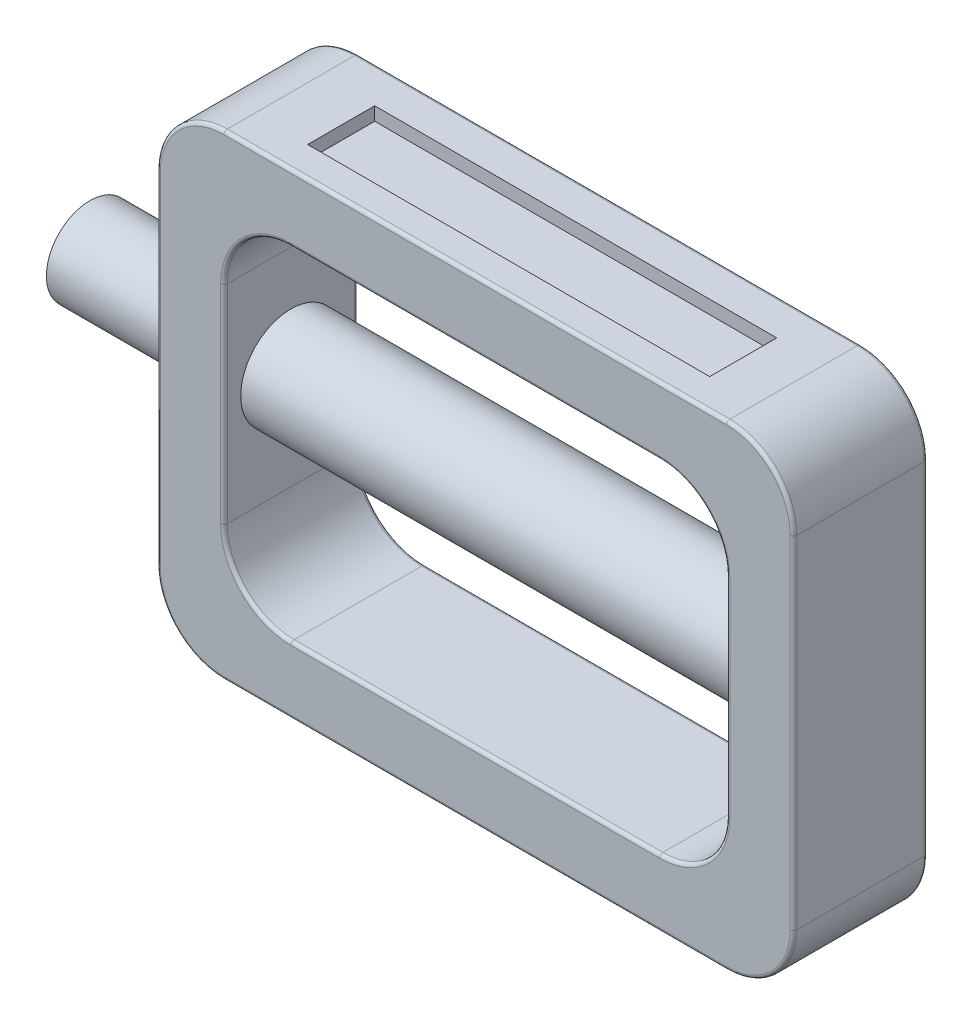
from build123d import *

# Parameters (mm, degrees)
BOSS_EXTRUDE1_DEPTH = 20
SKETCH2_R           = 7.5
BOSS_EXTRUDE2_DEPTH = 85
SKETCH4_R           = 6.5
BOSS_EXTRUDE3_DEPTH = 20
SKETCH5_W           = 60
SKETCH5_H           = 10
CUT_EXTRUDE1_DEPTH  = 2
FILLET1_R           = 0.5
FILLET2_R           = 0.5


with BuildPart() as part:
    # Sketch1 → Boss-Extrude1 (new body)
    with BuildSketch(Plane.XY):
        with BuildLine():
            Line((0, 0), (0, 25.5))
            ThreePointArc((0, 25.5), (2.928932188, 32.571067812), (10, 35.5))
            Line((10, 35.5), (85, 35.5))
            ThreePointArc((85, 35.5), (92.071067812, 32.571067812), (95, 25.5))
            Line((95, 25.5), (95, -25.5))
            ThreePointArc((95, -25.5), (92.071067812, -32.571067812), (85, -35.5))
            Line((85, -35.5), (10, -35.5))
            ThreePointArc((10, -35.5), (2.928932188, -32.571067812), (0, -25.5))
            Line((0, -25.5), (0, 0))
        make_face()
        with BuildLine():
            Line((10, 0), (10, 15.5))
            ThreePointArc((10, 15.5), (12.928932188, 22.571067812), (20, 25.5))
            Line((20, 25.5), (75, 25.5))
            ThreePointArc((75, 25.5), (82.071067812, 22.571067812), (85, 15.5))
            Line((85, 15.5), (85, 0))
            Line((85, 0), (85, -15.5))
            ThreePointArc((85, -15.5), (82.071067812, -22.571067812), (75, -25.5))
            Line((75, -25.5), (20, -25.5))
            ThreePointArc((20, -25.5), (12.928932188, -22.571067812), (10, -15.5))
            Line((10, -15.5), (10, 0))
        make_face(mode=Mode.SUBTRACT)
    extrude(amount=BOSS_EXTRUDE1_DEPTH)

    # Sketch2 → Boss-Extrude2 (add)
    with BuildSketch(Plane(origin=(0, 0, 0), x_dir=(0, 0, -1), z_dir=(1, 0, 0))):
        with Locations((-10, 0)):
            Circle(SKETCH2_R)
    extrude(amount=BOSS_EXTRUDE2_DEPTH)

    # Sketch4 → Boss-Extrude3 (add)
    with BuildSketch(Plane(origin=(0, 0, 0), x_dir=(0, 0, -1), z_dir=(1, 0, 0))):
        with Locations((-10, 0)):
            Circle(SKETCH4_R)
    extrude(amount=-BOSS_EXTRUDE3_DEPTH)

    # Sketch5 → Cut-Extrude1 (cut)
    with BuildSketch(Plane.XZ.offset(35.5)):
        with Locations((48, 10.5)):
            Rectangle(SKETCH5_W, SKETCH5_H)
    cut_extrude1 = extrude(amount=-CUT_EXTRUDE1_DEPTH, mode=Mode.SUBTRACT)

    # Mirror1: Cut-Extrude1 across plane
    add(cut_extrude1.mirror(Plane.ZX), mode=Mode.SUBTRACT)

    # Fillet1
    fillet1_edges = [part.edges().sort_by_distance(p)[0] for p in [
        (47.5, 35.5, 0),
        (92.071067812, 32.571067812, 0),
        (95, 0, 0),
        (92.071067812, -32.571067812, 0),
        (47.5, -35.5, 0),
        (2.928932188, -32.571067812, 0),
        (47.5, -35.5, 20),
        (92.071067812, -32.571067812, 20),
        (95, 0, 20),
        (92.071067812, 32.571067812, 20),
        (47.5, 35.5, 20),
        (2.928932188, 32.571067812, 20),
        (0, 0, 20),
        (2.928932188, -32.571067812, 20),
        (0, 0, 0),
        (2.928932188, 32.571067812, 0),
    ]]
    fillet(fillet1_edges, radius=FILLET1_R)

    # Fillet2
    fillet2_edges = [part.edges().sort_by_distance(p)[0] for p in [
        (12.928932188, -22.571067812, 0),
        (47.5, -25.5, 0),
        (82.071067812, -22.571067812, 0),
        (85, 0, 0),
        (82.071067812, 22.571067812, 0),
        (47.5, 25.5, 0),
        (12.928932188, 22.571067812, 0),
        (10, 0, 0),
        (10, 0, 20),
        (12.928932188, -22.571067812, 20),
        (47.5, -25.5, 20),
        (82.071067812, -22.571067812, 20),
        (85, 0, 20),
        (82.071067812, 22.571067812, 20),
        (47.5, 25.5, 20),
        (12.928932188, 22.571067812, 20),
    ]]
    fillet(fillet2_edges, radius=FILLET2_R)


solid = part.part
